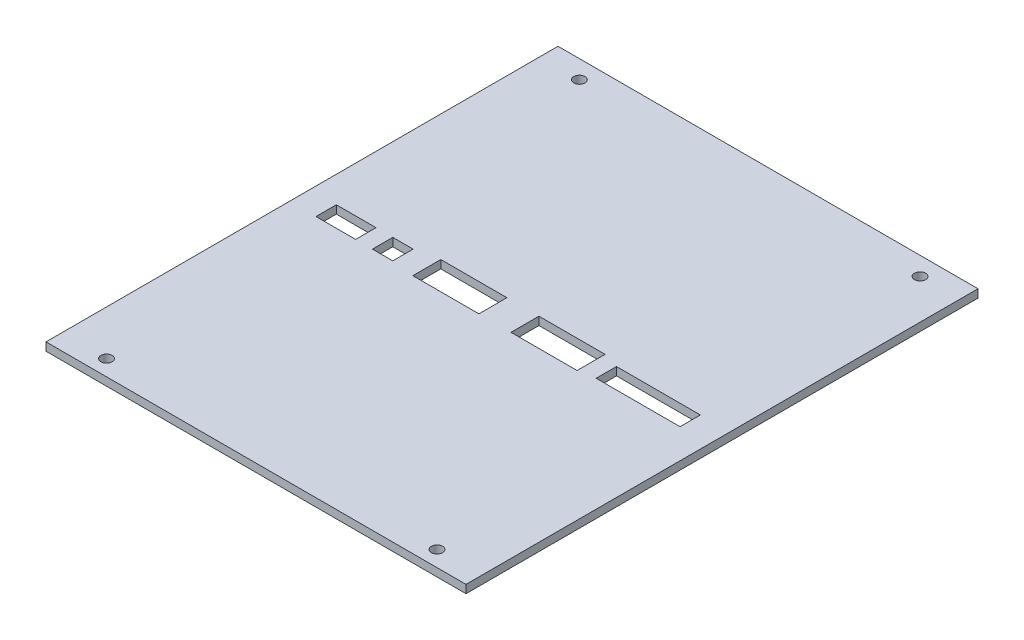
from build123d import *

# Parameters (mm, degrees)
BOSS_EXTRUDE1_DEPTH            = 1.6
SKETCH3_W                      = 13
SKETCH3_H                      = 5.5
SKETCH3_W_2                    = 16.5
SKETCH3_H_2                    = 4
SKETCH3_W_3                    = 7.8
SKETCH3_W_4                    = 4
CUT_EXTRUDE2_DEPTH             = 49
F_2_2_2_2_DIAMETER_HOLE2_D     = 2.2
F_2_2_2_2_DIAMETER_HOLE2_DEPTH = 5
CUT_EXTRUDE4_REACH             = 3.6
SKETCH12_W                     = 83
SKETCH12_H                     = 2.5
SKETCH_1_W                     = 83
SKETCH_1_H                     = 1.6
EXTRUDE_1_DEPTH                = 1.6
SKETCH_2_W                     = 83
SKETCH_2_H                     = 1.6
EXTRUDE_2_DEPTH                = 1.6
F_2_2_2_2_DIAMETER_HOLE1_D     = 2.2
F_2_2_2_2_DIAMETER_HOLE1_DEPTH = 1.6
SKETCH16_W                     = 0.2
SKETCH16_H                     = 100.7
EXTRUDE1_DEPTH                 = 2.6


with BuildPart() as part:
    # Sketch1 → Boss-Extrude1 (new body)
    with BuildSketch(Plane(origin=(0, 0, 0), x_dir=(1, 0, 0), z_dir=(0, 1, 0))):
        Polygon((65.24, 0.272495156), (65.24, -46.437452638), (65.24, -63.637452638), (65.24, -70.137452638), (-17.76, -70.137452638), (-17.76, -63.637452638), (-17.76, -48.637452638), (-17.76, -45.78978272), (-17.76, 4.362547362), (-17.76, 21.562547362), (-17.76, 29.862547362), (65.24, 29.862547362), (65.24, 21.562547362), (65.24, 6.562547362), align=None)
    extrude(amount=BOSS_EXTRUDE1_DEPTH)

    # Sketch3 → Cut-Extrude2 (cut)
    with BuildSketch(Plane(origin=(0, 1.6, 0), x_dir=(1, 0, 0), z_dir=(0, 1, 0))):
        with Locations((13.74, -19.137452638)):
            Rectangle(SKETCH3_W, SKETCH3_H)
        with Locations((50.99, -19.337452638)):
            Rectangle(SKETCH3_W_2, SKETCH3_H_2)
        with Locations((-8.46, -19.337452638)):
            Rectangle(SKETCH3_W_3, SKETCH3_H_2)
        with Locations((33.04, -19.137452638)):
            Rectangle(SKETCH3_W, SKETCH3_H)
        with Locations((0.74, -19.337452638)):
            Rectangle(SKETCH3_W_4, SKETCH3_H_2)
    extrude(amount=-CUT_EXTRUDE2_DEPTH, mode=Mode.SUBTRACT)

    # Ø2.2 (2.2) Diameter Hole2
    with Locations(Plane(origin=(0, 1.6, 0), x_dir=(1, 0, 0), z_dir=(0, 1, 0))):
        with Locations((56.24, -66.137452638), (-8.76, -66.137452638)):
            Hole(F_2_2_2_2_DIAMETER_HOLE2_D / 2, depth=F_2_2_2_2_DIAMETER_HOLE2_DEPTH)

    # Sketch12 → Cut-Extrude4 (cut, up to next)
    with BuildSketch(Plane(origin=(0, 1.6, 0), x_dir=(1, 0, 0), z_dir=(0, 1, 0)), mode=Mode.PRIVATE) as cut_extrude4_sk1:
        with Locations((23.74, -68.887452638)):
            Rectangle(SKETCH12_W, SKETCH12_H)
    cut_extrude4_tool1 = extrude(cut_extrude4_sk1.sketch, amount=-CUT_EXTRUDE4_REACH, mode=Mode.PRIVATE) & part.part
    add(cut_extrude4_tool1.solids().sort_by_distance((23.74, 1.6, 68.887453))[0], mode=Mode.SUBTRACT)

    # ｽｹｯﾁ1 → ﾎﾞｽ - 押し出し1 (add)
    with BuildSketch(Plane(origin=(0, 0, -29.862547362), x_dir=(-1, 0, 0), z_dir=(0, 0, -1))):
        with Locations((-23.74, 0.8)):
            Rectangle(SKETCH_1_W, SKETCH_1_H)
    extrude(amount=EXTRUDE_1_DEPTH)

    # ｽｹｯﾁ2 → ﾎﾞｽ - 押し出し2 (add)
    with BuildSketch(Plane.XY.offset(67.637452638)):
        with Locations((23.74, 0.8)):
            Rectangle(SKETCH_2_W, SKETCH_2_H)
    extrude(amount=EXTRUDE_2_DEPTH)

    # Ø2.2 (2.2) Diameter Hole1
    with Locations(Plane(origin=(0, 1.6, 0), x_dir=(1, 0, 0), z_dir=(0, 1, 0))):
        with Locations((-9.76, 27.862547362), (57.24, 27.862547362)):
            Hole(F_2_2_2_2_DIAMETER_HOLE1_D / 2, depth=F_2_2_2_2_DIAMETER_HOLE1_DEPTH)

    # Sketch16 → Extrude1 (cut, through all)
    with BuildSketch(Plane(origin=(0, 1.6, 0), x_dir=(1, 0, 0), z_dir=(0, 1, 0))):
        with Locations((-17.66, -18.887452638)):
            Rectangle(SKETCH16_W, SKETCH16_H)
        with Locations((65.14, -18.887452638)):
            Rectangle(SKETCH16_W, SKETCH16_H)
    extrude(amount=-EXTRUDE1_DEPTH, mode=Mode.SUBTRACT)


solid = part.part
